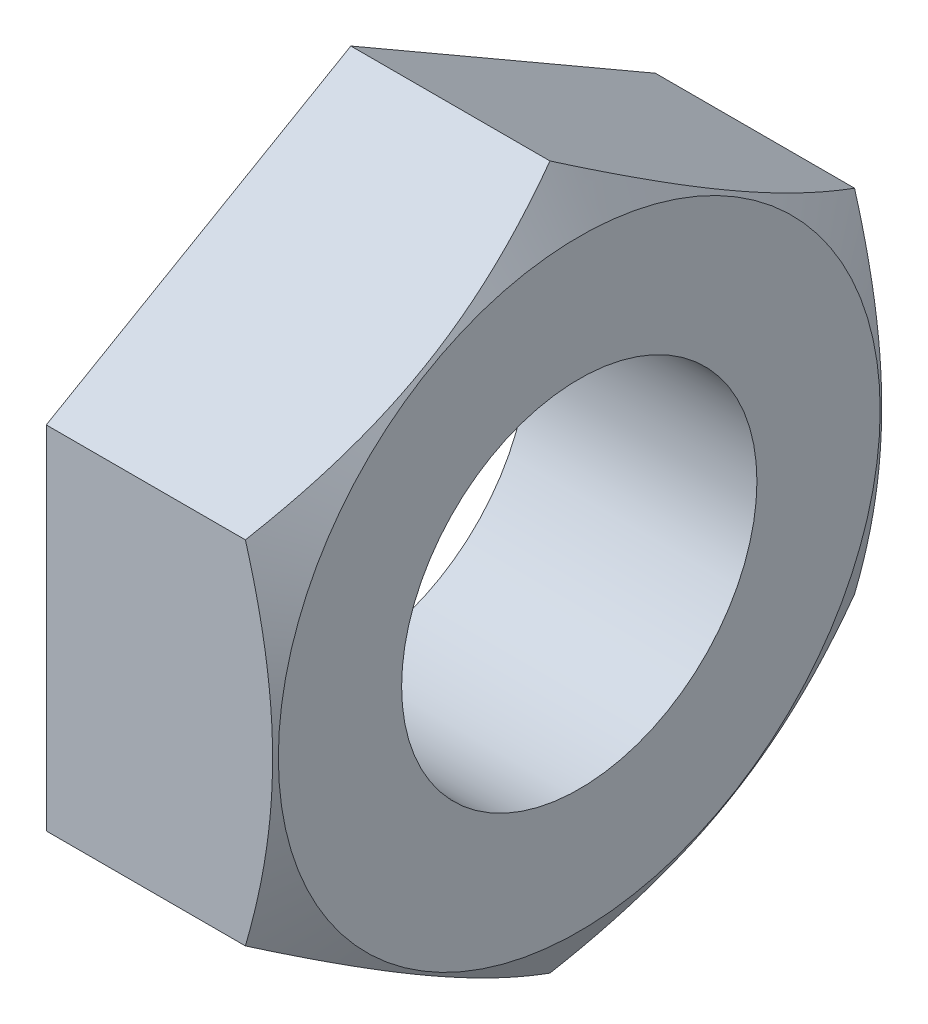
from build123d import *

# Parameters (mm, degrees)
BOSS_EXTRUDE1_DEPTH        = 9
M16X2_0_TAPPED_HOLE1_D     = 14
M16X2_0_TAPPED_HOLE1_DEPTH = 9


with BuildPart() as part:
    # Sketch1 → Boss-Extrude1 (new body)
    with BuildSketch(Plane(origin=(0, 0, 0), x_dir=(0, 0, -1), z_dir=(1, 0, 0))):
        Polygon((12, 6.92820323), (0, 13.856406461), (-12, 6.92820323), (-12, -6.92820323), (0, -13.856406461), (12, -6.92820323), align=None)
    extrude(amount=-BOSS_EXTRUDE1_DEPTH)

    # M16x2.0 Tapped Hole1
    with Locations(Plane(origin=(0, 0, 0), x_dir=(0, 0, -1), z_dir=(1, 0, 0))):
        with Locations((0, 0)):
            Hole(M16X2_0_TAPPED_HOLE1_D / 2, depth=M16X2_0_TAPPED_HOLE1_DEPTH)

    # Sketch10 → Cut-Revolve1 (revolve, cut)
    with BuildSketch(Plane.XY):
        Polygon((0, 13.856406461), (0, 11.856406461), (-1.154700538, 13.856406461), align=None)
    revolve(axis=Axis((0, 0, 0), (1, 0, 0)), mode=Mode.SUBTRACT)


solid = part.part
